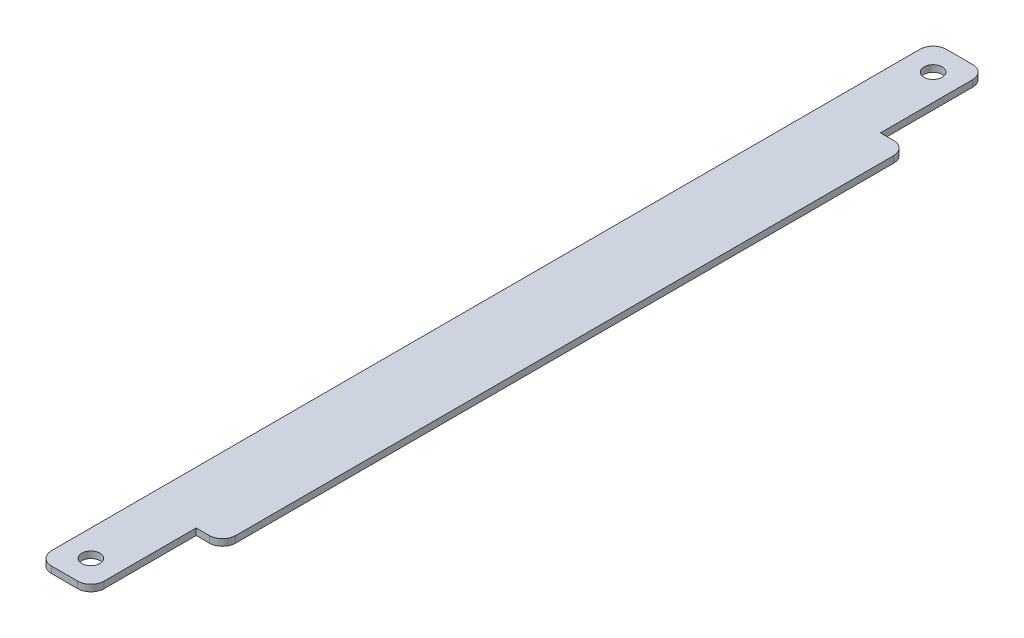
from build123d import *

# Parameters (mm, degrees)
SKETCH1_R           = 2.1828125
BOSS_EXTRUDE1_DEPTH = 1.5875


with BuildPart() as part:
    # Sketch1 → Boss-Extrude1 (new body)
    with BuildSketch(Plane(origin=(0, 0, 0), x_dir=(1, 0, 0), z_dir=(0, 1, 0))):
        with BuildLine():
            Line((0, 3.175), (0, 212.725))
            ThreePointArc((0, 212.725), (0.92993597, 214.97006403), (3.175, 215.9))
            Line((3.175, 215.9), (9.525, 215.9))
            ThreePointArc((9.525, 215.9), (11.77006403, 214.97006403), (12.7, 212.725))
            Line((12.7, 212.725), (12.7, 190.5))
            Line((12.7, 190.5), (15.875, 190.5))
            ThreePointArc((15.875, 190.5), (18.12006403, 189.57006403), (19.05, 187.325))
            Line((19.05, 187.325), (19.05, 28.575))
            ThreePointArc((19.05, 28.575), (18.12006403, 26.32993597), (15.875, 25.4))
            Line((15.875, 25.4), (12.7, 25.4))
            Line((12.7, 25.4), (12.7, 3.175))
            ThreePointArc((12.7, 3.175), (11.77006403, 0.92993597), (9.525, 0))
            Line((9.525, 0), (3.175, 0))
            ThreePointArc((3.175, 0), (0.92993597, 0.92993597), (0, 3.175))
        make_face()
        with Locations((6.35, 209.55)):
            Circle(SKETCH1_R, mode=Mode.SUBTRACT)
        with Locations((6.35, 6.35)):
            Circle(SKETCH1_R, mode=Mode.SUBTRACT)
    extrude(amount=BOSS_EXTRUDE1_DEPTH)


solid = part.part
